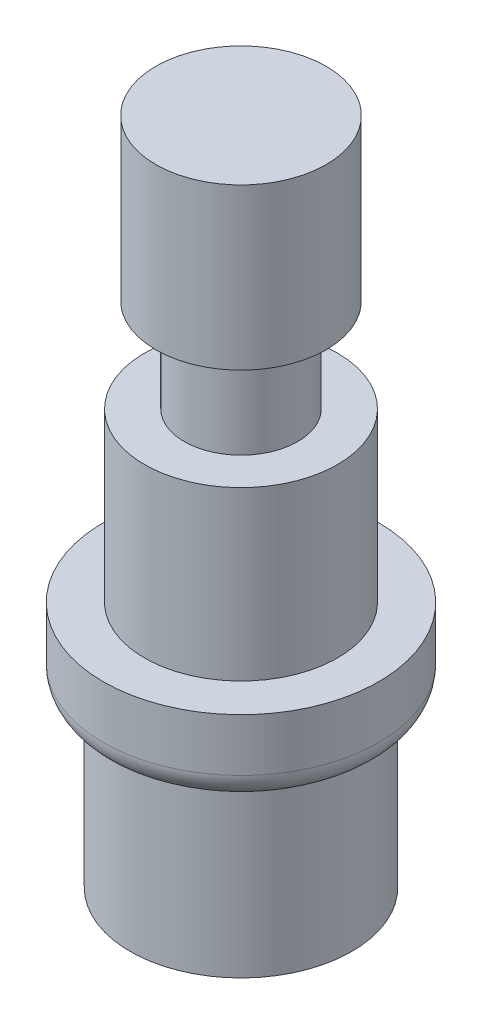
from build123d import *


with BuildPart() as part:
    # Sketch1 → Revolve1 (revolve)
    with BuildSketch(Plane.XY):
        with BuildLine():
            Line((0, 23.55), (3, 23.55))
            Line((3, 23.55), (3, 17.9))
            Line((3, 17.9), (2, 17.9))
            Line((2, 17.9), (2, 14.6))
            Line((2, 14.6), (3.4, 14.6))
            Line((3.4, 14.6), (3.4, 8.7))
            Line((3.4, 8.7), (4.85, 8.7))
            Line((4.85, 8.7), (4.85, 6.845))
            ThreePointArc((4.85, 6.845), (4.573215908, 6.176784092), (3.905, 5.9))
            Line((3.905, 5.9), (3.905, 0))
            Line((3.905, 0), (0, 0))
            Line((0, 0), (0, 23.55))
        make_face()
    revolve(axis=Axis((0, 0, 0), (0, 1, 0)))


solid = part.part
